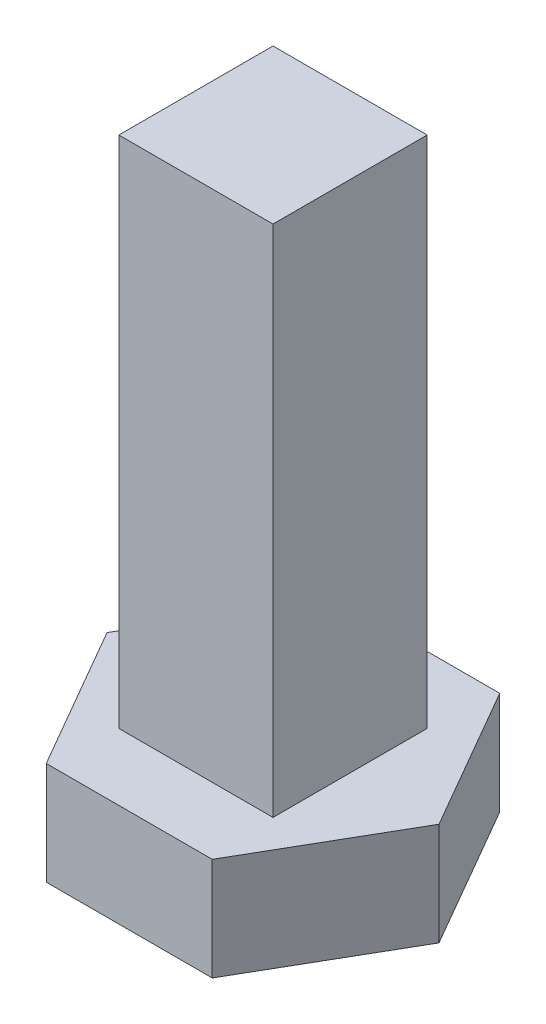
from build123d import *

# Parameters (mm, degrees)
EXTRUDE_1_DEPTH = 2
SKETCH_2_W      = 3
SKETCH_2_H      = 3
EXTRUDE_2_DEPTH = 10


with BuildPart() as part:
    # 스케치1 → 보스-돌출1 (new body)
    with BuildSketch(Plane(origin=(0, 0, 0), x_dir=(1, 0, 0), z_dir=(0, 1, 0))):
        Polygon((3.23, 0), (1.615, 2.797262054), (-1.615, 2.797262054), (-3.23, 0), (-1.615, -2.797262054), (1.615, -2.797262054), align=None)
    extrude(amount=EXTRUDE_1_DEPTH)

    # 스케치2 → 보스-돌출2 (add)
    with BuildSketch(Plane(origin=(0, 2, 0), x_dir=(1, 0, 0), z_dir=(0, 1, 0))):
        Rectangle(SKETCH_2_W, SKETCH_2_H)
    extrude(amount=EXTRUDE_2_DEPTH)


solid = part.part
